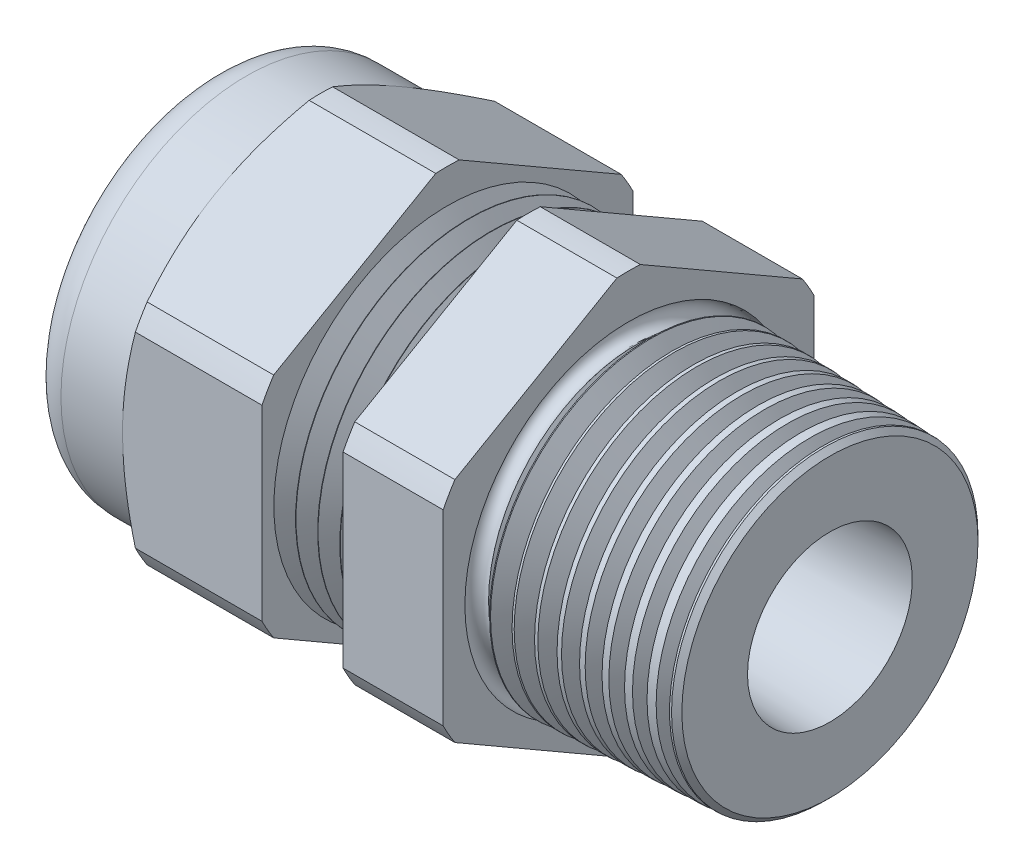
from build123d import *

# Parameters (mm, degrees)
SKETCH2_OUTSIDE_W  = 39.734
SKETCH2_OUTSIDE_H  = 39.734
CUT_EXTRUDE1_DEPTH = 20.6375
SKETCH14_W         = 6.2865
SKETCH14_H         = 1.397
CHAMFER1_SIZE      = 0.332311511
CHAMFER1_SIZE2     = 0.3175
SKETCH3_OUTSIDE_W  = 156.43
SKETCH3_OUTSIDE_H  = 159.296
SKETCH3_OUTSIDE_R  = 11.938
CUT_EXTRUDE2_DEPTH = 34.5915
CUT_EXTRUDE2_DRAFT = -60
SKETCH16_W         = 5.7785
SKETCH16_H         = 4.4069
FILLET1_R          = 2.32156
LPATTERN1_COUNT    = 4
LPATTERN1_PITCH    = 1.4224
LPATTERN2_COUNT    = 10
LPATTERN2_PITCH    = 1.4224
SKETCH15_R         = 0.635
FILLET4_R          = 0.254


with BuildPart() as part:
    # Sketch1 → Revolve1 (revolve)
    with BuildSketch(Plane.XY, mode=Mode.PRIVATE) as revolve1_sk:
        Polygon((-11.662833333, 11.17346), (-11.662833333, 13.37056), (-20.6375, 13.37056), (-20.6375, 10.541), (-26.924, 10.541), (-26.924, 8.8519), (-20.6375, 8.8519), (-20.6375, 4.445), (-11.662833333, 4.445), (12.954, 5.304638762), (12.954, 9.848416146), (0, 10.414), (0, 13.37056), (-6.444776119, 13.37056), (-6.444776119, 11.17346), align=None)
    revolve(revolve1_sk.sketch.rotate(Axis((-18.386021217, 0, 0), (1, 0, 0)), 90), axis=Axis((-18.386021217, 0, 0), (1, 0, 0)))  # turned: the seam where the file's is

    # Sketch2 outside → Cut-Extrude1 (cut)
    with BuildSketch(Plane(origin=(0, 0, 0), x_dir=(0, 0, -1), z_dir=(1, 0, 0))):
        Rectangle(SKETCH2_OUTSIDE_W, SKETCH2_OUTSIDE_H)
        with BuildLine():
            Line((11.938, -6.021298092), (11.938, 6.021298092))
            ThreePointArc((11.938, 6.021298092), (11.579244623, 6.68528), (11.183597111, 7.327962224))
            Line((11.183597111, 7.327962224), (0.754402889, 13.349260316))
            ThreePointArc((0.754402889, 13.349260316), (0, 13.37056), (-0.754402889, 13.349260316))
            Line((-0.754402889, 13.349260316), (-11.183597111, 7.327962224))
            ThreePointArc((-11.183597111, 7.327962224), (-11.579244623, 6.68528), (-11.938, 6.021298092))
            Line((-11.938, 6.021298092), (-11.938, -6.021298092))
            ThreePointArc((-11.938, -6.021298092), (-11.579244623, -6.68528), (-11.183597111, -7.327962224))
            Line((-11.183597111, -7.327962224), (-0.754402889, -13.349260316))
            ThreePointArc((-0.754402889, -13.349260316), (0, -13.37056), (0.754402889, -13.349260316))
            Line((0.754402889, -13.349260316), (11.183597111, -7.327962224))
            ThreePointArc((11.183597111, -7.327962224), (11.579244623, -6.68528), (11.938, -6.021298092))
        make_face(mode=Mode.SUBTRACT)
    extrude(amount=-CUT_EXTRUDE1_DEPTH, mode=Mode.SUBTRACT)

    # Sketch14 → Revolve4 (revolve)
    with BuildSketch(Plane.XY, mode=Mode.PRIVATE) as revolve4_sk:
        with Locations((-23.78075, 11.2395)):
            Rectangle(SKETCH14_W, SKETCH14_H)
    revolve(revolve4_sk.sketch.rotate(Axis((-18.386021217, 0, 0), (1, 0, 0)), 90), axis=Axis((-18.386021217, 0, 0), (1, 0, 0)))  # turned: the seam where the file's is

    # Chamfer1
    chamfer1_edges = [part.edges().sort_by_distance(p)[0] for p in [
        (12.954, 0, -9.848416146),
    ]]
    chamfer1_side = [part.faces().sort_by_distance(p)[0] for p in [
        (6.477, 0, -10.131208073),
    ]]
    chamfer(chamfer1_edges, length=CHAMFER1_SIZE, length2=CHAMFER1_SIZE2, reference=chamfer1_side[0])


with BuildPart() as cut_extrude2_tool:
    # Sketch3 outside → Cut-Extrude2 (with draft: the straight prism first)
    with BuildSketch(Plane.ZY.offset(20.6375)):
        Rectangle(SKETCH3_OUTSIDE_W, SKETCH3_OUTSIDE_H)
        Circle(SKETCH3_OUTSIDE_R, mode=Mode.SUBTRACT)
    extrude(amount=-CUT_EXTRUDE2_DEPTH)
    # Cut-Extrude2: the draft: its side faces are tilted about the plane it starts from
    cut_extrude2_sides = [cut_extrude2_tool.faces().sort_by_distance(p)[0] for p in [
        (-3.34175, -79.648, 0),
        (-3.34175, 0, 78.215),
        (-3.34175, 79.648, 0),
        (-3.34175, 0, -78.215),
        (-3.34175, 0, -11.938),
    ]]
    draft(cut_extrude2_sides, Plane.ZY.offset(20.6375), CUT_EXTRUDE2_DRAFT)


with BuildPart() as part_1:
    add(part.part)

    # Cut-Extrude2: cut by cut_extrude2_tool
    add(cut_extrude2_tool.part, mode=Mode.SUBTRACT)

    # Fillet1
    fillet1_edges = [part_1.edges().sort_by_distance(p)[0] for p in [
        (-26.924, 0, -11.938),
    ]]
    fillet(fillet1_edges, radius=FILLET1_R)

    # Sketch10 → Cut-Revolve1 (revolve, cut)
    with BuildSketch(Plane.XY):
        Polygon((-11.662833333, 11.17346), (-10.964333659, 9.963623075), (-10.265833985, 11.17346), align=None)
    cut_revolve1 = revolve(axis=Axis((15.58962545, 0, 0), (-1, 0, 0)), mode=Mode.SUBTRACT)

    # LPattern1: Cut-Revolve1 ×4
    with Locations(*[(i * LPATTERN1_PITCH, 0, 0) for i in range(1, LPATTERN1_COUNT)]):
        add(cut_revolve1, mode=Mode.SUBTRACT)

    # Sketch13 → Cut-Revolve2 (revolve, cut)
    with BuildSketch(Plane.XY, mode=Mode.PRIVATE) as cut_revolve2_sk:
        Polygon((0, 10.414), (1.39921935, 10.352908764), (0.717245196, 9.17169488), align=None)
    cut_revolve2 = revolve(cut_revolve2_sk.sketch.rotate(Axis((-18.386021217, 0, 0), (1, 0, 0)), 270), axis=Axis((-18.386021217, 0, 0), (1, 0, 0)), mode=Mode.SUBTRACT)  # turned: the seam where the file's is

    # LPattern2: Cut-Revolve2 ×10
    with Locations(*[(i * LPATTERN2_PITCH, 0, 0) for i in range(1, LPATTERN2_COUNT)]):
        add(cut_revolve2, mode=Mode.SUBTRACT)

    # Sketch15 → Cut-Revolve4 (revolve, cut)
    with BuildSketch(Plane.XY, mode=Mode.PRIVATE) as cut_revolve4_sk:
        with Locations((0, -9.906)):
            Circle(SKETCH15_R)
    revolve(cut_revolve4_sk.sketch.rotate(Axis((10.155027747, 0, 0), (-1, 0, 0)), 90), axis=Axis((10.155027747, 0, 0), (-1, 0, 0)), mode=Mode.SUBTRACT)  # turned: the seam where the file's is


with BuildPart() as body_2:
    # Sketch16 → Revolve5 (revolve)
    with BuildSketch(Plane.XY, mode=Mode.PRIVATE) as revolve5_sk:
        with Locations((-23.52675, 6.64845)):
            Rectangle(SKETCH16_W, SKETCH16_H)
    revolve(revolve5_sk.sketch.rotate(Axis((9.562227286, 0, 0), (-1, 0, 0)), 270), axis=Axis((9.562227286, 0, 0), (-1, 0, 0)))  # turned: the seam where the file's is

    # Fillet4
    fillet4_edges = [body_2.edges().sort_by_distance(p)[0] for p in [
        (-26.416, 0, -8.8519),
    ]]
    fillet(fillet4_edges, radius=FILLET4_R)


solid = Compound([part_1.part, body_2.part])
